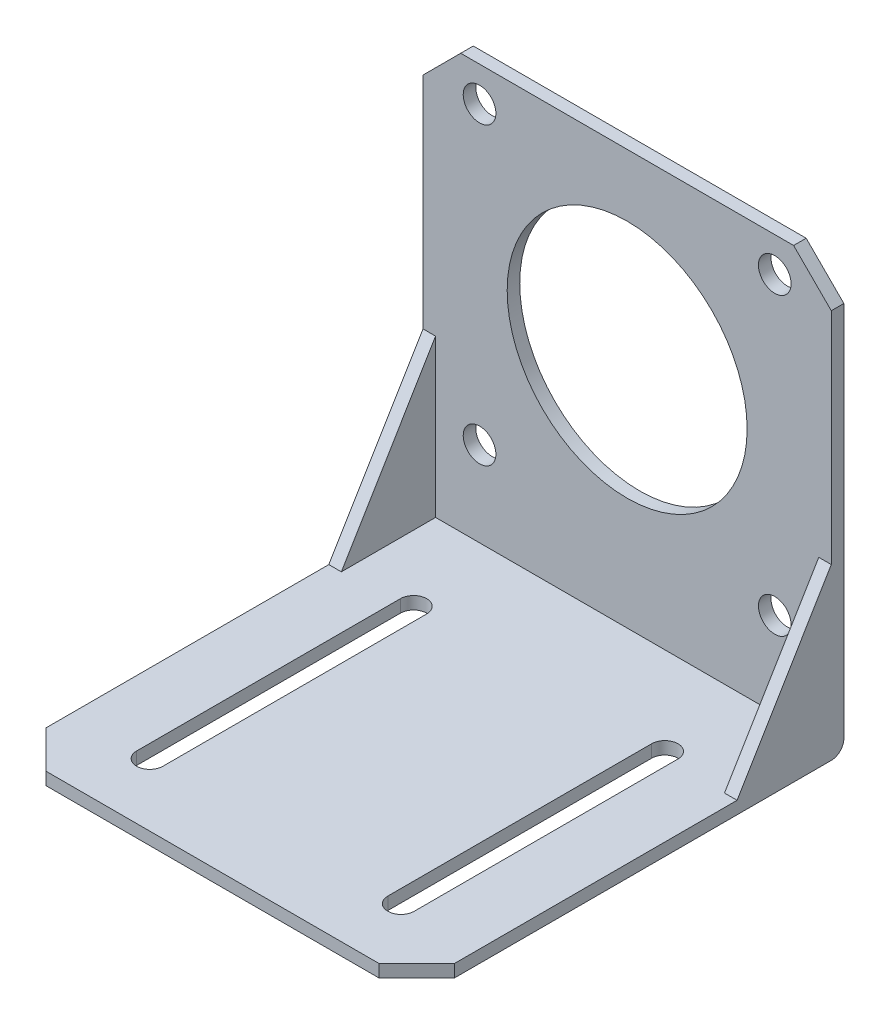
from build123d import *

# Parameters (mm, degrees)
EXTRUDE_1_DEPTH      = 32.5
CUT_EXTRUDE_3_DEPTH  = 30.5
EXTRUDE_2_DEPTH      = 68
CUT_EXTRUDE_8_DEPTH  = 69
SKETCH_11_R          = 19.1
SKETCH_11_R_2        = 2.6
CUT_EXTRUDE_10_DEPTH = 69
CHAMFER_1_SIZE       = 6
CHAMFER_2_SIZE       = 6
CHAMFER_3_SIZE       = 6
CHAMFER_4_SIZE       = 6
FILLET_1_R           = 2


with BuildPart() as part:
    # 草图1 → 凸台-拉伸1 (new body, symmetric)
    with BuildSketch(Plane(origin=(0, 0, 0), x_dir=(0, 0, -1), z_dir=(1, 0, 0))):
        Polygon((-68, 0), (0, 0), (0, 68), (-2, 68), (-2, 27), (-17, 2), (-68, 2), align=None)
    extrude(amount=EXTRUDE_1_DEPTH, both=True)

    # 草图6 → 切除-拉伸3 (cut, symmetric)
    with BuildSketch(Plane(origin=(0, 0, 0), x_dir=(0, 0, -1), z_dir=(1, 0, 0))):
        Polygon((-17, 2), (-2, 27), (-2, 2), align=None)
    extrude(amount=CUT_EXTRUDE_3_DEPTH, both=True, mode=Mode.SUBTRACT)

    # 草图7 → 凸台-拉伸2 (add, through all)
    with BuildSketch(Plane(origin=(0, 0, 0), x_dir=(1, 0, 0), z_dir=(0, 1, 0))):
        with BuildLine():
            Line((-17.9, -16), (-17.9, -58))
            ThreePointArc((-17.9, -58), (-20, -60.1), (-22.1, -58))
            Line((-22.1, -58), (-22.1, -16))
            ThreePointArc((-22.1, -16), (-20, -13.9), (-17.9, -16))
        make_face()
        with BuildLine():
            Line((17.9, -16), (17.9, -58))
            ThreePointArc((17.9, -58), (20, -60.1), (22.1, -58))
            Line((22.1, -58), (22.1, -16))
            ThreePointArc((22.1, -16), (20, -13.9), (17.9, -16))
        make_face()
    extrude(amount=EXTRUDE_2_DEPTH)

    # 草图10 → 切除-拉伸8 (cut, through all)
    with BuildSketch(Plane(origin=(0, 0, 0), x_dir=(1, 0, 0), z_dir=(0, 1, 0))):
        with BuildLine():
            Line((-17.9, -16), (-17.9, -58))
            ThreePointArc((-17.9, -58), (-20, -60.1), (-22.1, -58))
            Line((-22.1, -58), (-22.1, -16))
            ThreePointArc((-22.1, -16), (-20, -13.9), (-17.9, -16))
        make_face()
        with BuildLine():
            Line((17.9, -16), (17.9, -58))
            ThreePointArc((17.9, -58), (20, -60.1), (22.1, -58))
            Line((22.1, -58), (22.1, -16))
            ThreePointArc((22.1, -16), (20, -13.9), (17.9, -16))
        make_face()
    extrude(amount=CUT_EXTRUDE_8_DEPTH, mode=Mode.SUBTRACT)

    # 草图11 → 切除-拉伸10 (cut, through all)
    with BuildSketch(Plane.XY):
        with Locations((0, 39)):
            Circle(SKETCH_11_R)
        with Locations((-23.5, 62.5)):
            Circle(SKETCH_11_R_2)
        with Locations((23.5, 62.5)):
            Circle(SKETCH_11_R_2)
        with Locations((23.5, 15.5)):
            Circle(SKETCH_11_R_2)
        with Locations((-23.5, 15.5)):
            Circle(SKETCH_11_R_2)
    extrude(amount=CUT_EXTRUDE_10_DEPTH, mode=Mode.SUBTRACT)

    # 倒角1
    chamfer_1_edges = [part.edges().sort_by_distance(p)[0] for p in [
        (-32.5, 68, 1),
    ]]
    chamfer(chamfer_1_edges, length=CHAMFER_1_SIZE)

    # 倒角2
    chamfer_2_edges = [part.edges().sort_by_distance(p)[0] for p in [
        (32.5, 68, 1),
    ]]
    chamfer(chamfer_2_edges, length=CHAMFER_2_SIZE)

    # 倒角3
    chamfer_3_edges = [part.edges().sort_by_distance(p)[0] for p in [
        (-32.5, 1, 68),
    ]]
    chamfer(chamfer_3_edges, length=CHAMFER_3_SIZE)

    # 倒角4
    chamfer_4_edges = [part.edges().sort_by_distance(p)[0] for p in [
        (32.5, 1, 68),
    ]]
    chamfer(chamfer_4_edges, length=CHAMFER_4_SIZE)

    # 圆角1
    fillet_1_edges = [part.edges().sort_by_distance(p)[0] for p in [
        (0, 0, 0),
    ]]
    fillet(fillet_1_edges, radius=FILLET_1_R)


solid = part.part
